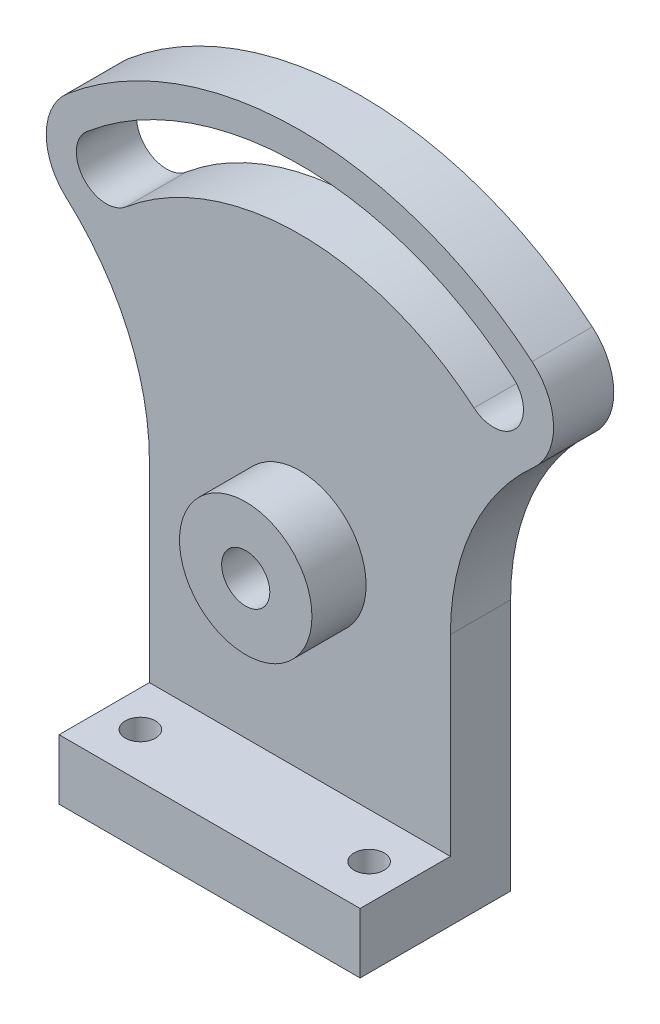
from build123d import *

# Parameters (mm, degrees)
SKETCH1_R           = 4
BOSS_EXTRUDE1_DEPTH = 10
SKETCH2_W           = 50
SKETCH2_H           = 10
BOSS_EXTRUDE2_DEPTH = 15
SKETCH3_R           = 2.5
CUT_EXTRUDE1_DEPTH  = 11
SKETCH4_R           = 11
SKETCH4_R_2         = 4
BOSS_EXTRUDE3_DEPTH = 9


with BuildPart() as part:
    # Sketch1 → Boss-Extrude1 (new body)
    with BuildSketch(Plane.XY):
        with BuildLine():
            Line((25, 0), (25, 41.903210357))
            ThreePointArc((25, 41.903210357), (28.610974366, 58.852541508), (38.81677775, 72.858273892))
            ThreePointArc((38.81677775, 72.858273892), (42.138016249, 80.467397369), (38.567256581, 87.962666587))
            ThreePointArc((38.567256581, 87.962666587), (0, 102), (-38.567256581, 87.962666587))
            ThreePointArc((-38.567256581, 87.962666587), (-42.138016249, 80.467397369), (-38.81677775, 72.858273892))
            ThreePointArc((-38.81677775, 72.858273892), (-28.610974366, 58.852541508), (-25, 41.903210357))
            Line((-25, 41.903210357), (-25, 0))
            Line((-25, 0), (25, 0))
        make_face()
        with Locations((0, 42)):
            Circle(SKETCH1_R, mode=Mode.SUBTRACT)
        with BuildLine():
            ThreePointArc((28.925442436, 76.47199994), (0, 87), (-28.925442436, 76.47199994))
            ThreePointArc((-28.925442436, 76.47199994), (-35.9696027, 77.088284108), (-35.353318533, 84.132444372))
            ThreePointArc((-35.353318533, 84.132444372), (0, 97), (35.353318533, 84.132444372))
            ThreePointArc((35.353318533, 84.132444372), (35.9696027, 77.088284108), (28.925442436, 76.47199994))
        make_face(mode=Mode.SUBTRACT)
    extrude(amount=BOSS_EXTRUDE1_DEPTH)

    # Sketch2 → Boss-Extrude2 (add)
    with BuildSketch(Plane.XY.offset(10)):
        with Locations((0, 5)):
            Rectangle(SKETCH2_W, SKETCH2_H)
    extrude(amount=BOSS_EXTRUDE2_DEPTH)

    # Sketch3 → Cut-Extrude1 (cut, through all)
    with BuildSketch(Plane(origin=(0, 10, 0), x_dir=(1, 0, 0), z_dir=(0, 1, 0))):
        with Locations((-19, -17.5)):
            Circle(SKETCH3_R)
        with Locations((19, -17.5)):
            Circle(SKETCH3_R)
    extrude(amount=-CUT_EXTRUDE1_DEPTH, mode=Mode.SUBTRACT)

    # Sketch4 → Boss-Extrude3 (add)
    with BuildSketch(Plane.XY.offset(10)):
        with Locations((0, 42)):
            Circle(SKETCH4_R)
        with Locations((0, 42)):
            Circle(SKETCH4_R_2, mode=Mode.SUBTRACT)
    extrude(amount=BOSS_EXTRUDE3_DEPTH)


solid = part.part
